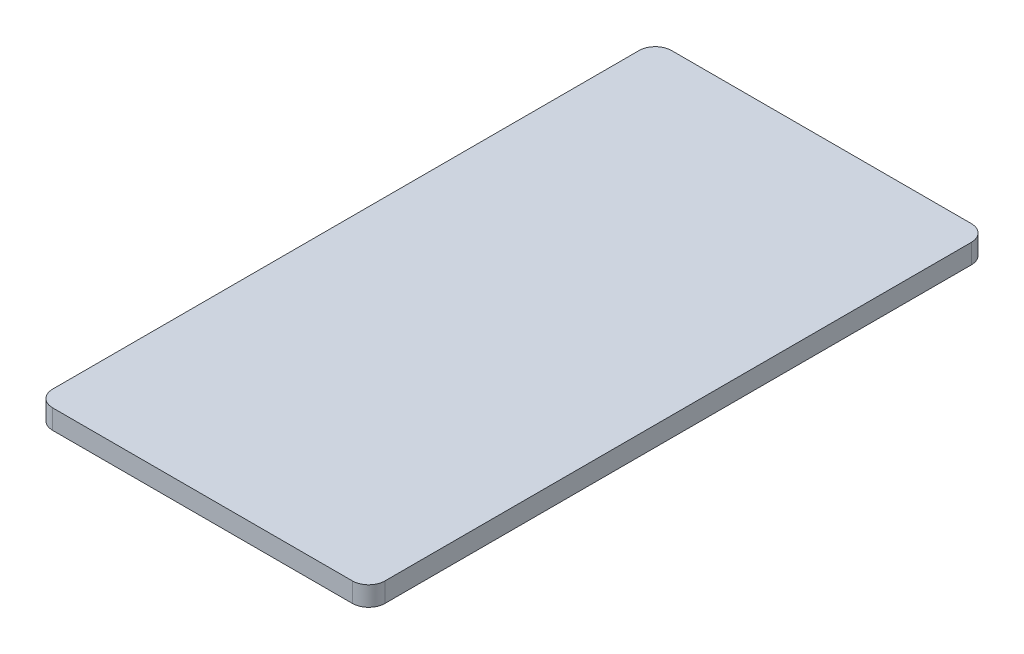
from build123d import *

# Parameters (mm, degrees)
BOSS_EXTRUDE1_DEPTH = 1.2


with BuildPart() as part:
    # Sketch1 → Boss-Extrude1 (new body)
    with BuildSketch(Plane.XZ.offset(-2.6)):
        with BuildLine():
            Line((10.4, -14), (10.4, 22))
            ThreePointArc((10.4, 22), (10.107106781, 22.707106781), (9.4, 23))
            Line((9.4, 23), (-9, 23))
            ThreePointArc((-9, 23), (-9.707106781, 22.707106781), (-10, 22))
            Line((-10, 22), (-10, -14))
            ThreePointArc((-10, -14), (-9.707106781, -14.707106781), (-9, -15))
            Line((-9, -15), (9.4, -15))
            ThreePointArc((9.4, -15), (10.107106781, -14.707106781), (10.4, -14))
        make_face()
    extrude(amount=-BOSS_EXTRUDE1_DEPTH)


solid = part.part
